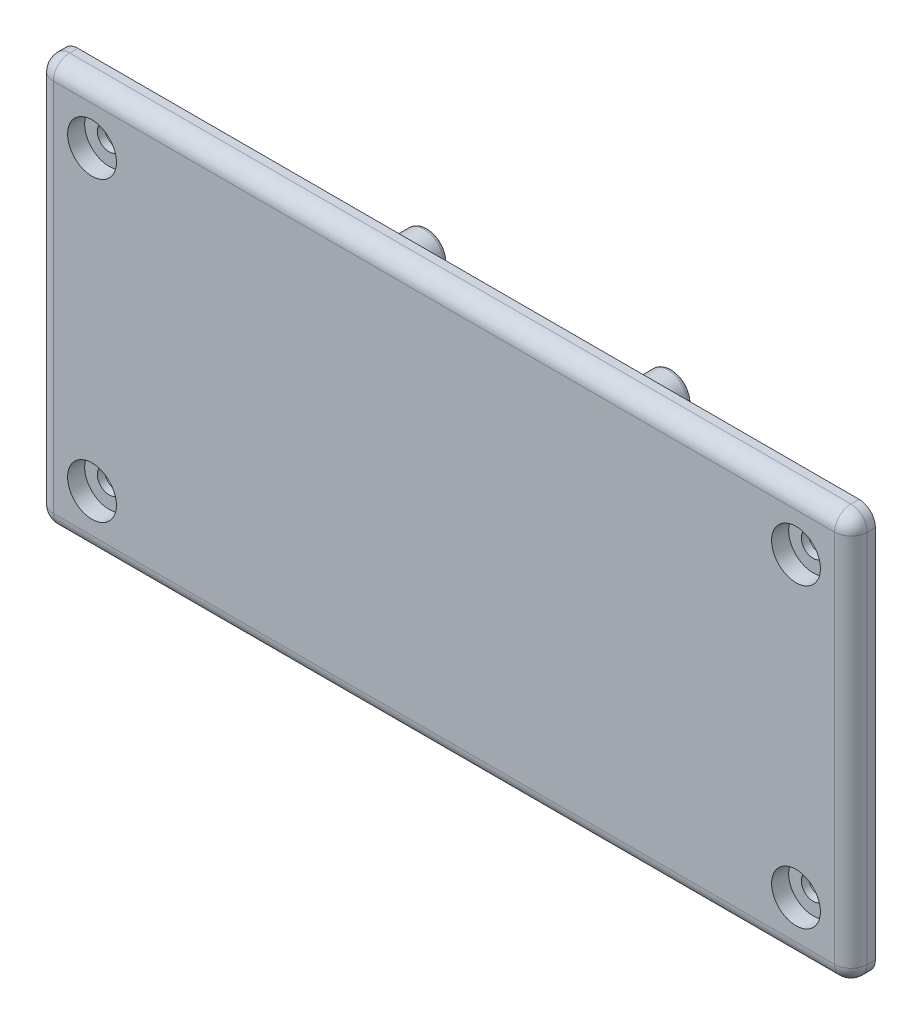
from build123d import *

# Parameters (mm, degrees)
BOSS_EXTRUDE1_DEPTH                                = 3
FILLET1_R                                          = 2
SKETCH2_W                                          = 10
SKETCH2_H                                          = 3
SKETCH2_W_2                                        = 3
SKETCH2_H_2                                        = 20
BOSS_EXTRUDE2_DEPTH                                = 1.5
FILLET2_R                                          = 1
SKETCH3_R                                          = 2.5099
BOSS_EXTRUDE3_DEPTH                                = 10
FILLET3_R                                          = 0.5
CBORE_FOR_M2_5_PAN_HEAD_MACHINE_SCREW1_D           = 2.9
CBORE_FOR_M2_5_PAN_HEAD_MACHINE_SCREW1_DEPTH       = 6.35
CBORE_FOR_M2_5_PAN_HEAD_MACHINE_SCREW1_CBORE_D     = 6
CBORE_FOR_M2_5_PAN_HEAD_MACHINE_SCREW1_CBORE_DEPTH = 2.1
CBORE_FOR_M2_5_PAN_HEAD_MACHINE_SCREW1_TIP         = 0.871247898


with BuildPart() as part:
    # Sketch1 → Boss-Extrude1 (new body)
    with BuildSketch(Plane.XY):
        with BuildLine():
            Line((-48, -25), (48, -25))
            ThreePointArc((48, -25), (49.414213562, -24.414213562), (50, -23))
            Line((50, -23), (50, 23))
            ThreePointArc((50, 23), (49.414213562, 24.414213562), (48, 25))
            Line((48, 25), (-48, 25))
            ThreePointArc((-48, 25), (-49.414213562, 24.414213562), (-50, 23))
            Line((-50, 23), (-50, -23))
            ThreePointArc((-50, -23), (-49.414213562, -24.414213562), (-48, -25))
        make_face()
    extrude(amount=BOSS_EXTRUDE1_DEPTH)

    # Fillet1
    fillet1_edges = [part.edges().sort_by_distance(p)[0] for p in [
        (49.414213562, -24.414213562, 3),
        (50, 0, 3),
        (49.414213562, 24.414213562, 3),
        (0, 25, 3),
        (-49.414213562, 24.414213562, 3),
        (-50, 0, 3),
        (-49.414213562, -24.414213562, 3),
        (0, -25, 3),
    ]]
    fillet(fillet1_edges, radius=FILLET1_R)

    # Sketch2 → Boss-Extrude2 (add)
    with BuildSketch(Plane(origin=(0, 0, 0), x_dir=(-1, 0, 0), z_dir=(0, 0, -1))):
        with Locations((-30, 20)):
            Rectangle(SKETCH2_W, SKETCH2_H)
        with Locations((-45, 0)):
            Rectangle(SKETCH2_W_2, SKETCH2_H_2)
        with Locations((-30, -20)):
            Rectangle(SKETCH2_W, SKETCH2_H)
        with Locations((30, -20)):
            Rectangle(SKETCH2_W, SKETCH2_H)
        with Locations((45, 0)):
            Rectangle(SKETCH2_W_2, SKETCH2_H_2)
        with Locations((30, 20)):
            Rectangle(SKETCH2_W, SKETCH2_H)
    extrude(amount=BOSS_EXTRUDE2_DEPTH)

    # Fillet2
    fillet2_edges = [part.edges().sort_by_distance(p)[0] for p in [
        (-30, 18.5, -1.5),
        (-25, 18.5, -0.75),
        (-35, 18.5, -0.75),
        (-35, 21.5, -0.75),
        (-25, 20, -1.5),
        (-25, 21.5, -0.75),
        (-35, 20, -1.5),
        (-30, 21.5, -1.5),
        (35, 20, -1.5),
        (35, 21.5, -0.75),
        (30, 18.5, -1.5),
        (35, 18.5, -0.75),
        (25, 18.5, -0.75),
        (25, 21.5, -0.75),
        (25, 20, -1.5),
        (30, 21.5, -1.5),
        (45, -10, -1.5),
        (46.5, -10, -0.75),
        (43.5, 0, -1.5),
        (43.5, -10, -0.75),
        (43.5, 10, -0.75),
        (46.5, 10, -0.75),
        (45, 10, -1.5),
        (46.5, 0, -1.5),
        (30, -18.5, -1.5),
        (25, -18.5, -0.75),
        (35, -18.5, -0.75),
        (35, -21.5, -0.75),
        (25, -20, -1.5),
        (25, -21.5, -0.75),
        (35, -20, -1.5),
        (30, -21.5, -1.5),
        (-30, -18.5, -1.5),
        (-35, -18.5, -0.75),
        (-25, -18.5, -0.75),
        (-25, -21.5, -0.75),
        (-35, -20, -1.5),
        (-35, -21.5, -0.75),
        (-25, -20, -1.5),
        (-30, -21.5, -1.5),
        (-43.5, 0, -1.5),
        (-43.5, 10, -0.75),
        (-43.5, -10, -0.75),
        (-46.5, -10, -0.75),
        (-45, 10, -1.5),
        (-46.5, 10, -0.75),
        (-45, -10, -1.5),
        (-46.5, 0, -1.5),
    ]]
    fillet(fillet2_edges, radius=FILLET2_R)

    # Sketch3 → Boss-Extrude3 (add)
    with BuildSketch(Plane(origin=(0, 0, 0), x_dir=(-1, 0, 0), z_dir=(0, 0, -1))):
        with Locations((-14.99997, -14.99997)):
            Circle(SKETCH3_R)
        with Locations((-14.99997, 14.99997)):
            Circle(SKETCH3_R)
        with Locations((14.99997, -14.99997)):
            Circle(SKETCH3_R)
        with Locations((14.99997, 14.99997)):
            Circle(SKETCH3_R)
    extrude(amount=BOSS_EXTRUDE3_DEPTH)

    # Fillet3
    fillet3_edges = [part.edges().sort_by_distance(p)[0] for p in [
        (17.50987, -14.99997, -10),
        (17.50987, 14.99997, -10),
        (-12.49007, -14.99997, -10),
        (-12.49007, 14.99997, -10),
    ]]
    fillet(fillet3_edges, radius=FILLET3_R)

    # CBORE for M2.5 Pan Head Machine Screw1
    with Locations(Plane(origin=(43.250058959, -18.25, 3), x_dir=(1, 0, 0), z_dir=(0, 0, 1))):
        with Locations((0, 0), (0, 36.5), (-86.500117918, 0), (-86.500117918, 36.5)):
            CounterBoreHole(CBORE_FOR_M2_5_PAN_HEAD_MACHINE_SCREW1_D / 2, CBORE_FOR_M2_5_PAN_HEAD_MACHINE_SCREW1_CBORE_D / 2, CBORE_FOR_M2_5_PAN_HEAD_MACHINE_SCREW1_CBORE_DEPTH, depth=CBORE_FOR_M2_5_PAN_HEAD_MACHINE_SCREW1_DEPTH)
            with Locations((0, 0, -(CBORE_FOR_M2_5_PAN_HEAD_MACHINE_SCREW1_DEPTH + CBORE_FOR_M2_5_PAN_HEAD_MACHINE_SCREW1_TIP / 2))):  # 118° drill point
                Cone(0, CBORE_FOR_M2_5_PAN_HEAD_MACHINE_SCREW1_D / 2, CBORE_FOR_M2_5_PAN_HEAD_MACHINE_SCREW1_TIP, mode=Mode.SUBTRACT)


solid = part.part
